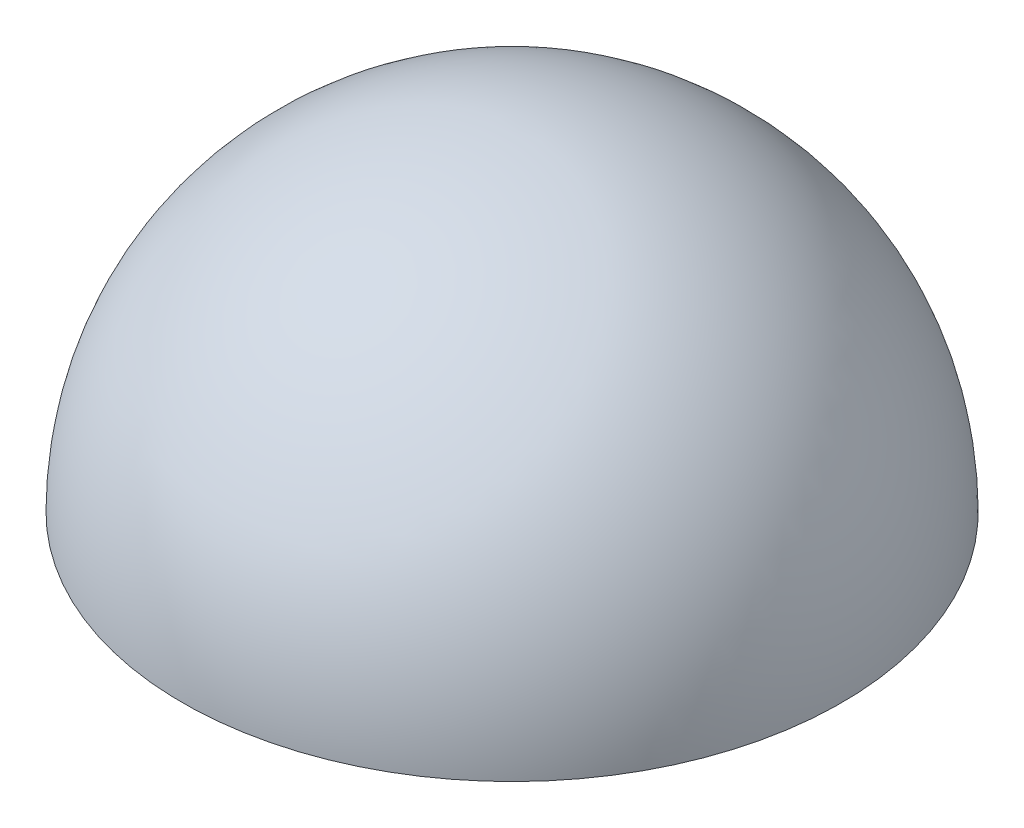
from build123d import *

# Parameters (mm, degrees)
REVOLVE1_ANGLE = 180


with BuildPart() as part:
    # Sketch2 → Revolve1 (revolve)
    with BuildSketch(Plane(origin=(0, 0, 0), x_dir=(1, 0, 0), z_dir=(0, 1, 0))):
        with BuildLine():
            Line((0, 4597.4), (0, 4622.8))
            ThreePointArc((0, 4622.8), (4622.8, 0), (0, -4622.8))
            Line((0, -4622.8), (0, -4597.4))
            ThreePointArc((0, -4597.4), (4597.4, 0), (0, 4597.4))
        make_face()
    revolve(axis=Axis((0, 0, 0), (0, 0, 1)), revolution_arc=REVOLVE1_ANGLE)


solid = part.part
